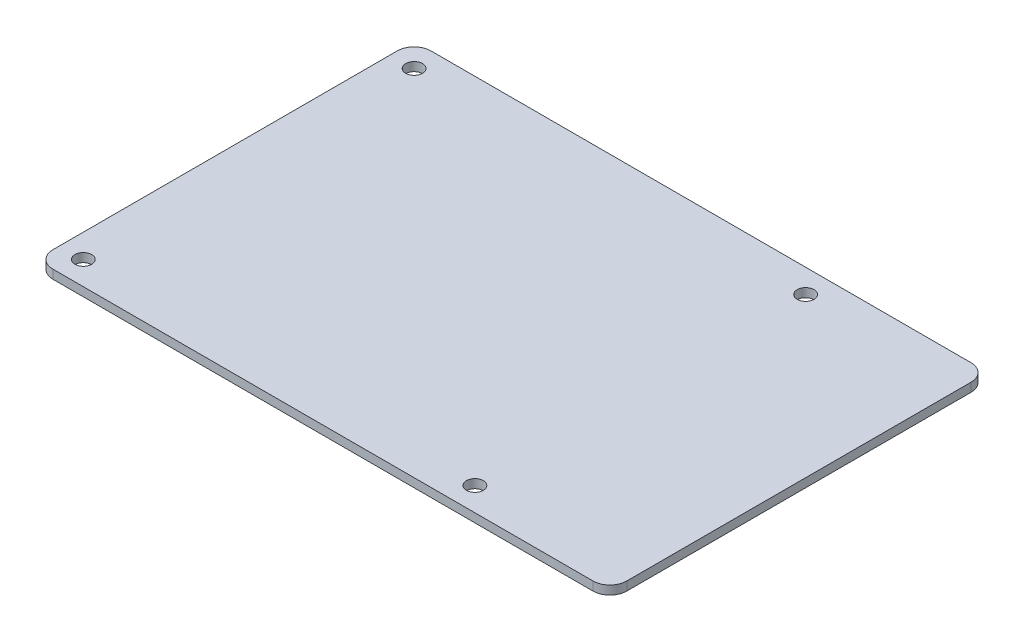
from build123d import *

# Parameters (mm, degrees)
SCHIZZO1_R                   = 1.25
ESTRUSIONE_ESTRUSIONE1_DEPTH = 1.3


with BuildPart() as part:
    # Schizzo1 → Estrusione-Estrusione1 (new body)
    with BuildSketch(Plane(origin=(0, 0, 0), x_dir=(1, 0, 0), z_dir=(0, 1, 0))):
        with BuildLine():
            Line((42.5, -25.5), (42.5, 25.5))
            ThreePointArc((42.5, 25.5), (41.767766953, 27.267766953), (40, 28))
            Line((40, 28), (-40, 28))
            ThreePointArc((-40, 28), (-41.767766953, 27.267766953), (-42.5, 25.5))
            Line((-42.5, 25.5), (-42.5, -25.5))
            ThreePointArc((-42.5, -25.5), (-41.767766953, -27.267766953), (-40, -28))
            Line((-40, -28), (40, -28))
            ThreePointArc((40, -28), (41.767766953, -27.267766953), (42.5, -25.5))
        make_face()
        with Locations((19, 24.5)):
            Circle(SCHIZZO1_R, mode=Mode.SUBTRACT)
        with Locations((-39, 24.5)):
            Circle(SCHIZZO1_R, mode=Mode.SUBTRACT)
        with Locations((-39, -24.5)):
            Circle(SCHIZZO1_R, mode=Mode.SUBTRACT)
        with Locations((19, -24.5)):
            Circle(SCHIZZO1_R, mode=Mode.SUBTRACT)
    extrude(amount=-ESTRUSIONE_ESTRUSIONE1_DEPTH)


solid = part.part
